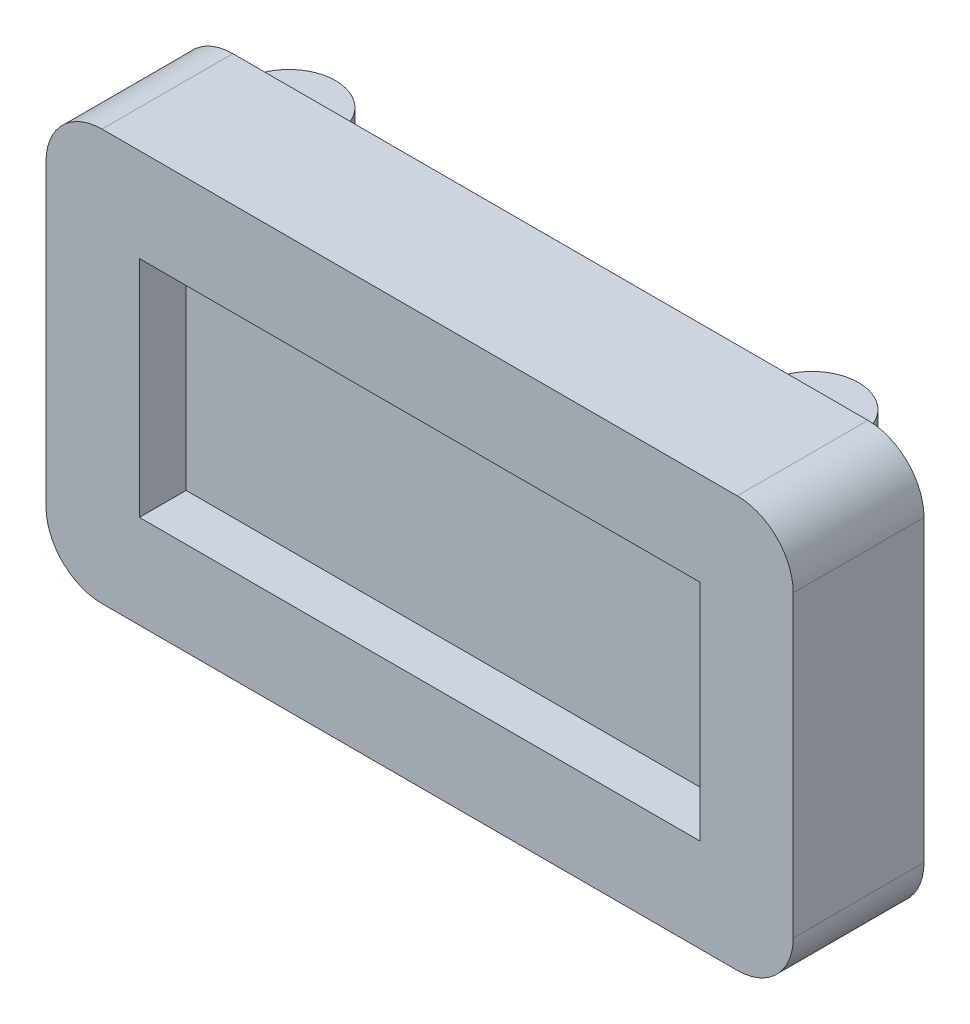
from build123d import *

# Parameters (mm, degrees)
SKETCH1_W           = 40
SKETCH1_H           = 22
BOSS_EXTRUDE1_DEPTH = 7
FILLET1_R           = 3
SKETCH3_W           = 30
SKETCH3_H           = 12
CUT_EXTRUDE1_DEPTH  = 2.5
BOSS_EXTRUDE2_DEPTH = 1


with BuildPart() as part:
    # Sketch1 → Boss-Extrude1 (new body)
    with BuildSketch(Plane.XY):
        with Locations((20, 11)):
            Rectangle(SKETCH1_W, SKETCH1_H)
    extrude(amount=BOSS_EXTRUDE1_DEPTH)

    # Fillet1
    fillet1_edges = [part.edges().sort_by_distance(p)[0] for p in [
        (0, 22, 3.5),
        (40, 22, 3.5),
        (40, 0, 3.5),
        (0, 0, 3.5),
    ]]
    fillet(fillet1_edges, radius=FILLET1_R)

    # Sketch3 → Cut-Extrude1 (cut)
    with BuildSketch(Plane.XY.offset(7)):
        with Locations((20, 11)):
            Rectangle(SKETCH3_W, SKETCH3_H)
    extrude(amount=-CUT_EXTRUDE1_DEPTH, mode=Mode.SUBTRACT)

    # Sketch4 → Boss-Extrude2 (add)
    with BuildSketch(Plane(origin=(0, 21, 0), x_dir=(1, 0, 0), z_dir=(0, 1, 0))):
        with BuildLine():
            ThreePointArc((31.5, 0), (34, -2.5), (36.5, 0))
            Line((36.5, 0), (31.5, 0))
        make_face()
        with BuildLine():
            Line((31.5, 0), (36.5, 0))
            ThreePointArc((36.5, 0), (34, 2.5), (31.5, 0))
        make_face()
        with BuildLine():
            ThreePointArc((3.5, 0), (6, -2.5), (8.5, 0))
            Line((8.5, 0), (3.5, 0))
        make_face()
        with BuildLine():
            Line((3.5, 0), (8.5, 0))
            ThreePointArc((8.5, 0), (6, 2.5), (3.5, 0))
        make_face()
    boss_extrude2 = extrude(amount=-BOSS_EXTRUDE2_DEPTH)

    # Mirror1: Boss-Extrude2 across plane
    add(boss_extrude2.mirror(Plane(origin=(0, 11, 0), x_dir=(0, 0, 1), z_dir=(0, -1, 0))))


solid = part.part
